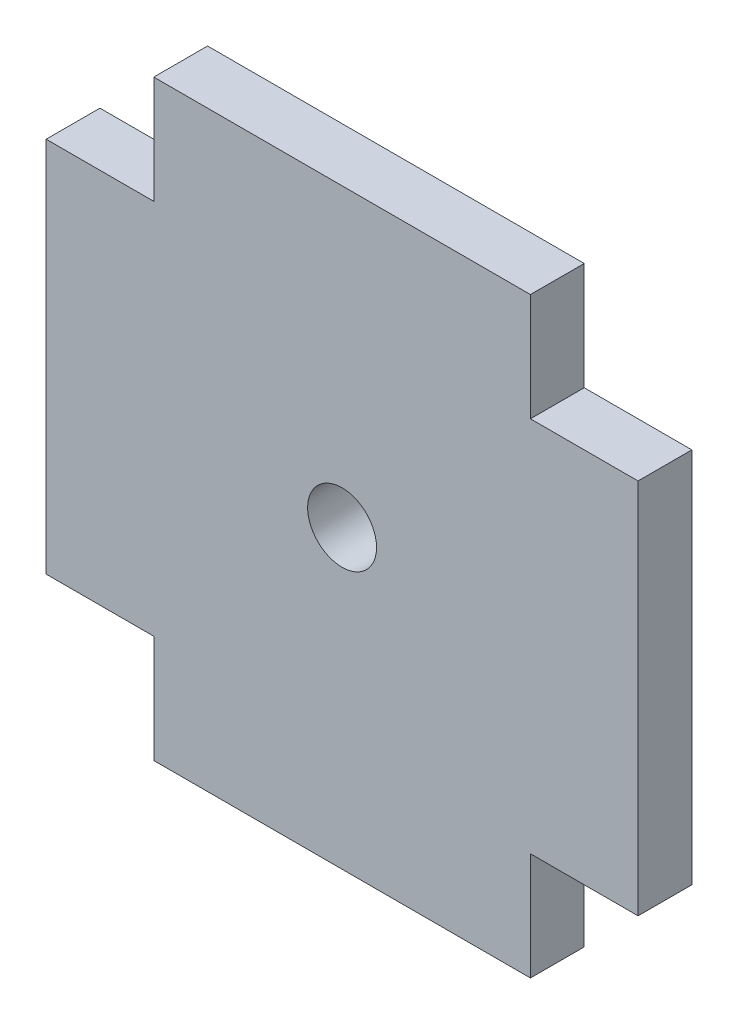
from build123d import *

# Parameters (mm, degrees)
SKETCH1_R           = 3.2
BOSS_EXTRUDE1_DEPTH = 5


with BuildPart() as part:
    # Sketch1 → Boss-Extrude1 (new body)
    with BuildSketch(Plane.XY):
        Polygon((-17.5, 27.5), (17.5, 27.5), (17.5, 17.5), (27.5, 17.5), (27.5, -17.5), (17.5, -17.5), (17.5, -27.5), (-17.5, -27.5), (-17.5, -17.5), (-27.5, -17.5), (-27.5, 17.5), (-17.5, 17.5), align=None)
        Circle(SKETCH1_R, mode=Mode.SUBTRACT)
    extrude(amount=-BOSS_EXTRUDE1_DEPTH)


solid = part.part
